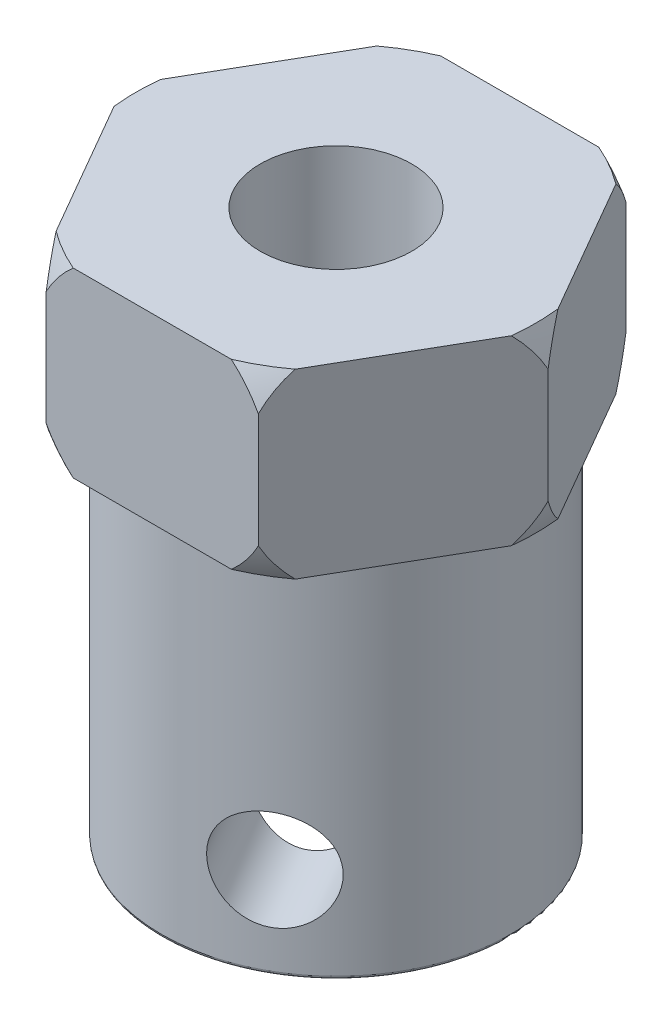
from build123d import *

# Parameters (mm, degrees)
EXTRUDE_1_DEPTH     = 6
SKETCH_2_R          = 5.75
EXTRUDE_2_DEPTH     = 12
SKETCH_3_R          = 2.5
CUT_EXTRUDE_1_DEPTH = 29
SKETCH_5_R          = 1.65
CUT_EXTRUDE_2_DEPTH = 3.5
FILLET_2_R          = 0.1


with BuildPart() as part:
    # 草图1 → 凸台-拉伸1 (new body)
    with BuildSketch(Plane(origin=(0, 0, 0), x_dir=(1, 0, 0), z_dir=(0, 1, 0))):
        Polygon((-3.5, -6.062177826), (3.5, -6.062177826), (7, 0), (3.5, 6.062177826), (-3.5, 6.062177826), (-7, 0), align=None)
    extrude(amount=EXTRUDE_1_DEPTH)

    # 草图2 → 凸台-拉伸2 (add)
    with BuildSketch(Plane.XZ):
        Circle(SKETCH_2_R)
    extrude(amount=EXTRUDE_2_DEPTH)

    # 草图3 → 切除-拉伸1 (cut)
    with BuildSketch(Plane(origin=(0, 6, 0), x_dir=(1, 0, 0), z_dir=(0, 1, 0))):
        Circle(SKETCH_3_R)
    extrude(amount=-CUT_EXTRUDE_1_DEPTH, mode=Mode.SUBTRACT)

    # 草图4 → 切除-旋转1 (revolve, cut)
    with BuildSketch(Plane.XY):
        with BuildLine():
            Line((-7, 0), (-6.600189391, 0))
            ThreePointArc((-6.600189391, 0), (-6.822809169, 0.548107865), (-7, 1.112541391))
            Line((-7, 1.112541391), (-7, 0))
        make_face()
        with BuildLine():
            Line((-7, 6), (-7, 4.887458609))
            ThreePointArc((-7, 4.887458609), (-6.822809169, 5.451892135), (-6.600189391, 6))
            Line((-6.600189391, 6), (-7, 6))
        make_face()
    revolve(axis=Axis((0, -23, 0), (0, 1, 0)), mode=Mode.SUBTRACT)

    # 草图5 → 切除-拉伸2 (cut, symmetric)
    with BuildSketch(Plane(origin=(1.75, 0, 3.031088913), x_dir=(0.866025404, 0, -0.5), z_dir=(0.5, 0, 0.866025404))):
        with Locations((0, -9)):
            Circle(SKETCH_5_R)
    extrude(amount=CUT_EXTRUDE_2_DEPTH, both=True, mode=Mode.SUBTRACT)

    # 圆角2
    fillet_2_edges = [part.edges().sort_by_distance(p)[0] for p in [
        (-5.75, -12, 0),
        (-2.5, -12, 0),
    ]]
    fillet(fillet_2_edges, radius=FILLET_2_R)


solid = part.part
